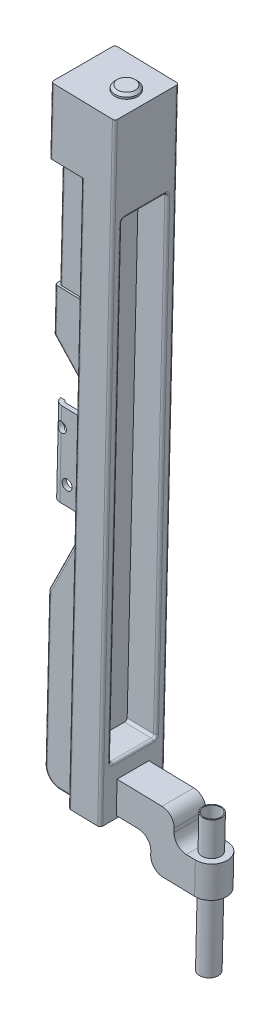
from build123d import *

# Parameters (mm, degrees)
SKETCH1_R                = 4
BOSS_EXTRUDE1_DEPTH      = 51
SKETCH4_W                = 25.4
SKETCH4_H                = 8.5
CUT_EXTRUDE3_DEPTH       = 440.98
SKETCH6_W                = 34
SKETCH6_H                = 440.98
BOSS_EXTRUDE2_DEPTH      = 2
CUT_EXTRUDE4_DEPTH       = 93.5
CUT_EXTRUDE5_DEPTH       = 51
BOSS_EXTRUDE3_REACH      = 427.853
SKETCH9_W                = 8
SKETCH9_H                = 23.2
CUT_EXTRUDE6_REACH       = 398.253
FILLET2_R                = 2
SKETCH12_W               = 36
SKETCH12_H               = 380.35245688
CUT_EXTRUDE7_DEPTH       = 23
FILLET3_R                = 2
SKETCH13_R               = 9.1
BOSS_EXTRUDE4_DEPTH      = 3.5
CHAMFER1_SIZE            = 2
BOSS_EXTRUDE5_DEPTH      = 12.7
SKETCH15_R               = 7.5
CUT_EXTRUDE8_DEPTH       = 25.4
SKETCH16_R               = 7.5
SKETCH16_R_2             = 6.75
BOSS_EXTRUDE6_DEPTH      = 58
BOSS_EXTRUDE6_DEPTH_BACK = 52.4
CUT_EXTRUDE9_DEPTH       = 58


with BuildPart() as part:
    # Sketch1 → Boss-Extrude1 (new body)
    with BuildSketch(Plane.XY):
        Polygon((279.154476391, 74.287149039), (290.935576931, 568.09909232), (239.950084792, 569.315476851), (228.168984252, 75.50353357), align=None)
        with Locations((244.2699, 289.1803)):
            Circle(SKETCH1_R, mode=Mode.SUBTRACT)
        with Locations((239.6933, 326.7526)):
            Circle(SKETCH1_R, mode=Mode.SUBTRACT)
    extrude(amount=BOSS_EXTRUDE1_DEPTH)

    # Sketch4 → Cut-Extrude3 (cut)
    with BuildSketch(Plane(origin=(1.930093146, 80.901019715, 0), x_dir=(0.9997155321405113, -0.023850677076640778, 0), z_dir=(-0.023850677076640778, -0.9997155321405113, 0))):
        with Locations((239.003267112, 4.25)):
            Rectangle(SKETCH4_W, SKETCH4_H)
        with Locations((239.003267112, 46.75)):
            Rectangle(SKETCH4_W, SKETCH4_H)
    extrude(amount=-CUT_EXTRUDE3_DEPTH, mode=Mode.SUBTRACT)

    # Sketch6 → Boss-Extrude2 (add)
    with BuildSketch(Plane(origin=(226.238891106, -5.397486145, 0), x_dir=(0, 0, 1), z_dir=(-0.9997155321405113, 0.023850677076640812, 0))):
        with Locations((25.5, 301.414040003)):
            Rectangle(SKETCH6_W, SKETCH6_H)
    extrude(amount=BOSS_EXTRUDE2_DEPTH)

    # Sketch7 → Cut-Extrude4 (cut)
    with BuildSketch(Plane(origin=(12.447764723, 521.755575078, 0), x_dir=(0.9997155321405113, -0.023850677076640885, 0), z_dir=(-0.023850677076640885, -0.9997155321405113, 0))):
        Polygon((226.303267112, 0), (251.703267112, 0), (251.703267112, 8.5), (251.703267112, 10.15), (226.303267112, 10.15), (226.303267112, 40.85), (251.703267112, 40.85), (251.703267112, 42.5), (251.703267112, 51), (226.303267112, 51), (198.098576295, 28.203747717), align=None)
    extrude(amount=CUT_EXTRUDE4_DEPTH, mode=Mode.SUBTRACT)

    # Sketch8 → Cut-Extrude5 (cut)
    with BuildSketch(Plane.XY.offset(51)):
        Polygon((258.308043507, 273.841117268), (233.914984522, 274.423073789), (234.808250977, 311.864876648), (233.337246651, 311.89997108), (234.052766963, 341.891437045), (259.916830274, 341.274386091), (260.5376048, 367.294525212), (252.5376048, 367.485384923), (233.621755839, 387.914809122), (229.365543916, 209.513116231), (249.761753677, 251.038465445), (257.759477934, 250.847660029), align=None)
        with BuildLine():
            Line((253.561758768, 74.897726372), (211.511167859, 59.235236696))
            Line((211.511167859, 59.235236696), (211.511167859, 108.385384029))
            Line((211.511167859, 108.385384029), (226.455761313, 87.54782131))
            ThreePointArc((226.455761313, 87.54782131), (229.767100408, 78.981125306), (238.166139573, 75.265026799))
            Line((238.166139573, 75.265026799), (253.561758768, 74.897726372))
        make_face()
    extrude(amount=-CUT_EXTRUDE5_DEPTH, mode=Mode.SUBTRACT)

    # Boss-Extrude3: up to this face of the body (flat: up to its plane)
    boss_extrude3_end = Plane(part.part.faces().sort_by_distance((256.5376048, 367.389955068, 25.5))[0])
    # Sketch9 → Boss-Extrude3 (add, up to the picked face)
    with BuildSketch(Plane(origin=(6.127812311, 256.850953372, 0), x_dir=(0.9997155321405112, -0.02385067707664364, 0), z_dir=(0.023850677076643644, 0.9997155321405113, 0)), mode=Mode.PRIVATE) as boss_extrude3_sk1:
        with Locations((247.703267112, -25.5)):
            Rectangle(SKETCH9_W, SKETCH9_H)
    boss_extrude3_tool1 = split(extrude(boss_extrude3_sk1.sketch, amount=BOSS_EXTRUDE3_REACH, mode=Mode.PRIVATE), bisect_by=boss_extrude3_end, keep=Keep.BOTH, mode=Mode.PRIVATE)
    add(boss_extrude3_tool1.solids().sort_by(Axis((253.760616, 250.943063, 25.5), (0.023850677076643644, 0.9997155321405113, 0)))[0])

    # Cut-Extrude6: up to this face of the body (flat: up to its plane)
    cut_extrude6_end = Plane(part.part.faces().sort_by_distance((243.748956464, 274.188460159, 25.5))[0])
    # Sketch10 → Cut-Extrude6 (cut, up to the picked face)
    with BuildSketch(Plane(origin=(8.285164651, 347.277679435, 0), x_dir=(0.9997155321405115, -0.023850677076639768, 0), z_dir=(0.023850677076639768, 0.9997155321405115, 0)), mode=Mode.PRIVATE) as cut_extrude6_sk1:
        with BuildLine():
            Line((231.831844213, -39), (240.203267112, -39))
            Line((240.203267112, -39), (251.703267112, -39))
            Line((251.703267112, -39), (251.703267112, -37.1))
            Line((251.703267112, -37.1), (243.703267112, -37.1))
            Line((243.703267112, -37.1), (243.703267112, -13.9))
            Line((243.703267112, -13.9), (251.703267112, -13.9))
            Line((251.703267112, -13.9), (251.702324012, -12))
            Line((251.702324012, -12), (240.203267112, -12))
            Line((240.203267112, -12), (231.831844213, -12))
            ThreePointArc((231.831844213, -12), (230.46253782, -12.408349934), (229.540556366, -13.5))
            Line((229.540556366, -13.5), (225.91576443, -13.5))
            ThreePointArc((225.91576443, -13.5), (227.958860867, -9.917424305), (231.831844213, -8.5))
            Line((231.831844213, -8.5), (226.321029693, -3.613917465))
            Line((226.321029693, -3.613917465), (220.596449647, -10.474152147))
            Line((220.596449647, -10.474152147), (219.260507843, -48.239271178))
            Line((219.260507843, -48.239271178), (231.831844213, -42.5))
            ThreePointArc((231.831844213, -42.5), (227.958860867, -41.082575695), (225.91576443, -37.5))
            Line((225.91576443, -37.5), (229.540556366, -37.5))
            ThreePointArc((229.540556366, -37.5), (230.46253782, -38.591650066), (231.831844213, -39))
        make_face()
    cut_extrude6_tool1 = split(extrude(cut_extrude6_sk1.sketch, amount=-CUT_EXTRUDE6_REACH, mode=Mode.PRIVATE), bisect_by=cut_extrude6_end, keep=Keep.BOTH, mode=Mode.PRIVATE)
    add(cut_extrude6_tool1.solids().sort_by(Axis((239.708563, 341.756504, 25.989439), (-0.023850677076639768, -0.9997155321405115, 0)))[0], mode=Mode.SUBTRACT)

    # Fillet2
    fillet2_edges = [part.edges().sort_by_distance(p)[0] for p in [
        (227.910652614, 148.53046877, 8.5),
        (227.910652614, 148.53046877, 42.5),
        (234.039471148, 405.423598577, 42.5),
        (255.660618351, 162.8726932, 42.5),
        (245.863949171, 75.081376586, 42.5),
        (245.863949171, 75.081376586, 8.5),
        (239.563648796, 230.275790838, 8.5),
        (239.563648796, 230.275790838, 42.5),
        (243.079680319, 377.700097022, 8.5),
        (243.079680319, 377.700097022, 42.5),
        (239.318370311, 542.836782892, 51),
        (229.767100408, 78.981125306, 8.5),
        (229.767100408, 78.981125306, 42.5),
        (251.15081711, 309.261898037, 37.1),
        (251.15081711, 309.261898037, 13.9),
        (285.045026661, 321.19312068, 51),
        (258.820594557, 295.325004054, 0),
        (258.820594557, 295.325004054, 51),
        (253.561758768, 74.897726372, 46.75),
        (234.039471148, 405.423598577, 8.5),
        (285.045026661, 321.19312068, 0),
        (237.571636676, 469.621387806, 10.15),
        (237.571636676, 469.621387806, 40.85),
        (239.318370311, 542.836782892, 0),
    ]]
    fillet(fillet2_edges, radius=FILLET2_R)

    # Sketch12 → Cut-Extrude7 (cut)
    with BuildSketch(Plane(origin=(277.224383245, -6.613870676, 0), x_dir=(0, 0, -1), z_dir=(0.9997155321405113, -0.023850677076640923, 0))):
        with Locations((-25.5, 311.700268443)):
            Rectangle(SKETCH12_W, SKETCH12_H)
    extrude(amount=-CUT_EXTRUDE7_DEPTH, mode=Mode.SUBTRACT)

    # Fillet3
    fillet3_edges = [part.edges().sort_by_distance(p)[0] for p in [
        (268.626085261, 115.14988243, 43.5),
        (277.697748885, 495.39414126, 43.5),
        (277.697748885, 495.39414126, 7.5),
        (268.626085261, 115.14988243, 7.5),
        (284.658645693, 304.997729059, 43.5),
        (280.122813881, 114.875599644, 25.5),
        (284.658645693, 304.997729059, 7.5),
        (289.194477505, 495.119858474, 25.5),
    ]]
    fillet(fillet3_edges, radius=FILLET3_R)

    # Sketch13 → Boss-Extrude4 (add)
    with BuildSketch(Plane(origin=(13.711193686, 574.712962996, 0), x_dir=(0.9997155321405115, -0.02385067707664048, 0), z_dir=(0.02385067707664048, 0.9997155321405115, 0))):
        with Locations((260.803267112, -25.5)):
            Circle(SKETCH13_R)
    extrude(amount=BOSS_EXTRUDE4_DEPTH)

    # Chamfer1
    chamfer1_edges = [part.edges().sort_by_distance(p)[0] for p in [
        (265.426336678, 572.208674016, 25.5),
    ]]
    chamfer(chamfer1_edges, length=CHAMFER1_SIZE)

    # Sketch14 → Boss-Extrude5 (add, symmetric)
    with BuildSketch(Plane(origin=(0, 0, 25.5), x_dir=(-1, 0, 0), z_dir=(0, 0, -1))):
        with BuildLine():
            Line((-279.202177745, 76.286580103), (-279.807984943, 101.67935462))
            Line((-279.807984943, 101.67935462), (-315.547815217, 100.826692914))
            ThreePointArc((-315.547815217, 100.826692914), (-322.547014522, 97.729944158), (-325.306463768, 90.591030822))
            Line((-325.306463768, 90.591030822), (-325.232526669, 87.491912672))
            ThreePointArc((-325.232526669, 87.491912672), (-327.991975915, 80.352999336), (-334.991175219, 77.25625058))
            Line((-334.991175219, 77.25625058), (-342.239112828, 77.083333171))
            Line((-342.239112828, 77.083333171), (-341.63330563, 51.690558655))
            Line((-341.63330563, 51.690558655), (-316.390488443, 52.292788251))
            ThreePointArc((-316.390488443, 52.292788251), (-309.391289139, 55.389537007), (-306.631839893, 62.528450343))
            Line((-306.631839893, 62.528450343), (-306.705776992, 65.627568493))
            ThreePointArc((-306.705776992, 65.627568493), (-303.946327745, 72.766481829), (-296.947128441, 75.863230585))
            Line((-296.947128441, 75.863230585), (-279.202177745, 76.286580103))
        make_face()
        Polygon((-341.63330563, 51.690558655), (-342.239112828, 77.083333171), (-354.935500086, 76.780429572), (-354.329692888, 51.387655056), align=None)
    extrude(amount=BOSS_EXTRUDE5_DEPTH, both=True)

    # Sketch15 → Cut-Extrude8 (cut)
    with BuildSketch(Plane(origin=(1.42684386, 59.807021987, 0), x_dir=(0.9997155321405115, -0.023850677076641066, 0), z_dir=(-0.023850677076641066, -0.9997155321405115, 0))):
        with Locations((340.303267112, 25.5)):
            Circle(SKETCH15_R)
    extrude(amount=-CUT_EXTRUDE8_DEPTH, mode=Mode.SUBTRACT)

    # Sketch16 → Boss-Extrude6 (add, two sides)
    with BuildSketch(Plane(origin=(1.42684386, 59.807021987, 0), x_dir=(0.9997155321405113, -0.02385067707664106, 0), z_dir=(-0.02385067707664106, -0.9997155321405113, 0))) as boss_extrude6_sk:
        with Locations((340.303267112, 25.5)):
            Circle(SKETCH16_R)
        with Locations((340.303267112, 25.5)):
            Circle(SKETCH16_R_2, mode=Mode.SUBTRACT)
    extrude(amount=BOSS_EXTRUDE6_DEPTH)
    extrude(boss_extrude6_sk.sketch, amount=-BOSS_EXTRUDE6_DEPTH_BACK)

    # Sketch17 → Cut-Extrude9 (cut)
    with BuildSketch(Plane(origin=(1.42684386, 59.807021987, 0), x_dir=(0.9997155321405113, -0.02385067707664106, 0), z_dir=(-0.02385067707664106, -0.9997155321405113, 0))):
        with BuildLine():
            ThreePointArc((353.003267112, 25.5), (349.283523233, 16.519743879), (340.303267112, 12.8))
            Line((340.303267112, 12.8), (353.003267112, 12.8))
            Line((353.003267112, 12.8), (353.003267112, 25.5))
        make_face()
        with BuildLine():
            Line((353.003267112, 38.2), (340.303267112, 38.2))
            ThreePointArc((340.303267112, 38.2), (349.283523233, 34.480256121), (353.003267112, 25.5))
            Line((353.003267112, 25.5), (353.003267112, 38.2))
        make_face()
    extrude(amount=-CUT_EXTRUDE9_DEPTH, mode=Mode.SUBTRACT)


solid = part.part
